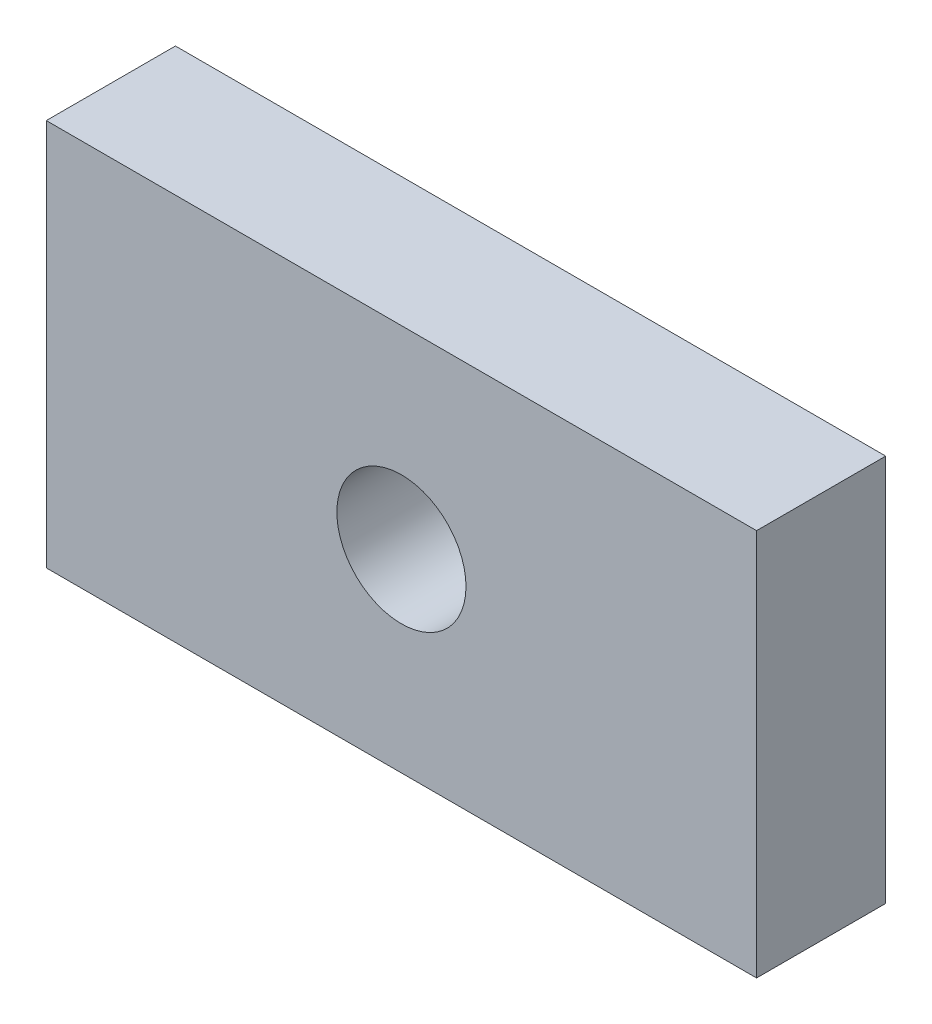
from build123d import *

# Parameters (mm, degrees)
SKETCH1_W           = 139.7
SKETCH1_H           = 76.2
SKETCH1_R           = 12.7
BOSS_EXTRUDE2_DEPTH = 25.4


with BuildPart() as part:
    # Sketch1 → Boss-Extrude2 (new body)
    with BuildSketch(Plane.XY):
        Rectangle(SKETCH1_W, SKETCH1_H)
        Circle(SKETCH1_R, mode=Mode.SUBTRACT)
    extrude(amount=BOSS_EXTRUDE2_DEPTH)


solid = part.part
